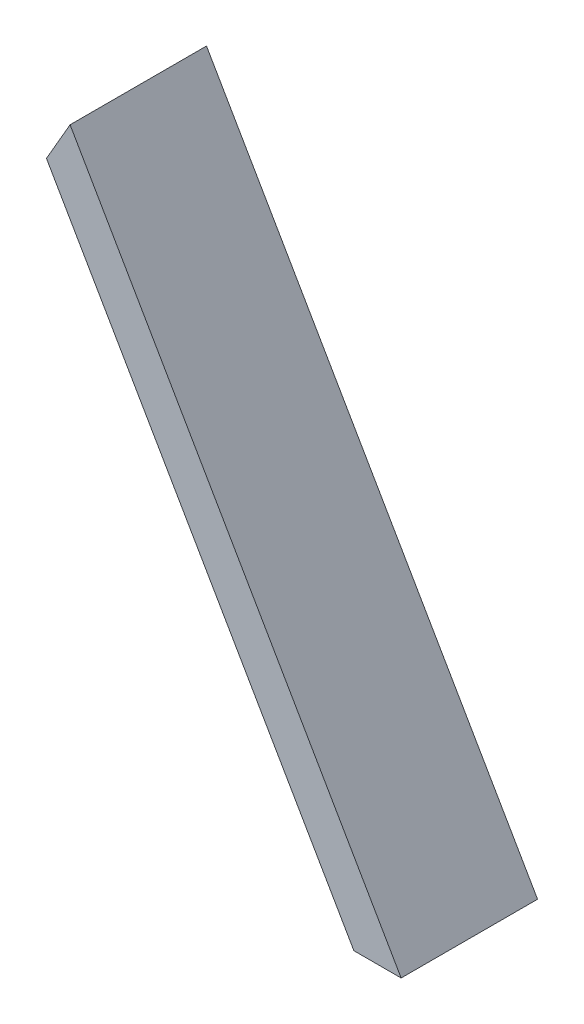
from build123d import *

# Parameters (mm, degrees)
BOSS_EXTRUDE1_DEPTH = 63.5


with BuildPart() as part:
    # Sketch2 → Boss-Extrude1 (new body)
    with BuildSketch(Plane.XY):
        Polygon((82.550000001, -133.455794165), (-71.551477371, 133.455794166), (-82.55, 114.405794164), (60.552954744, -133.455794165), align=None)
    extrude(amount=BOSS_EXTRUDE1_DEPTH)


solid = part.part
